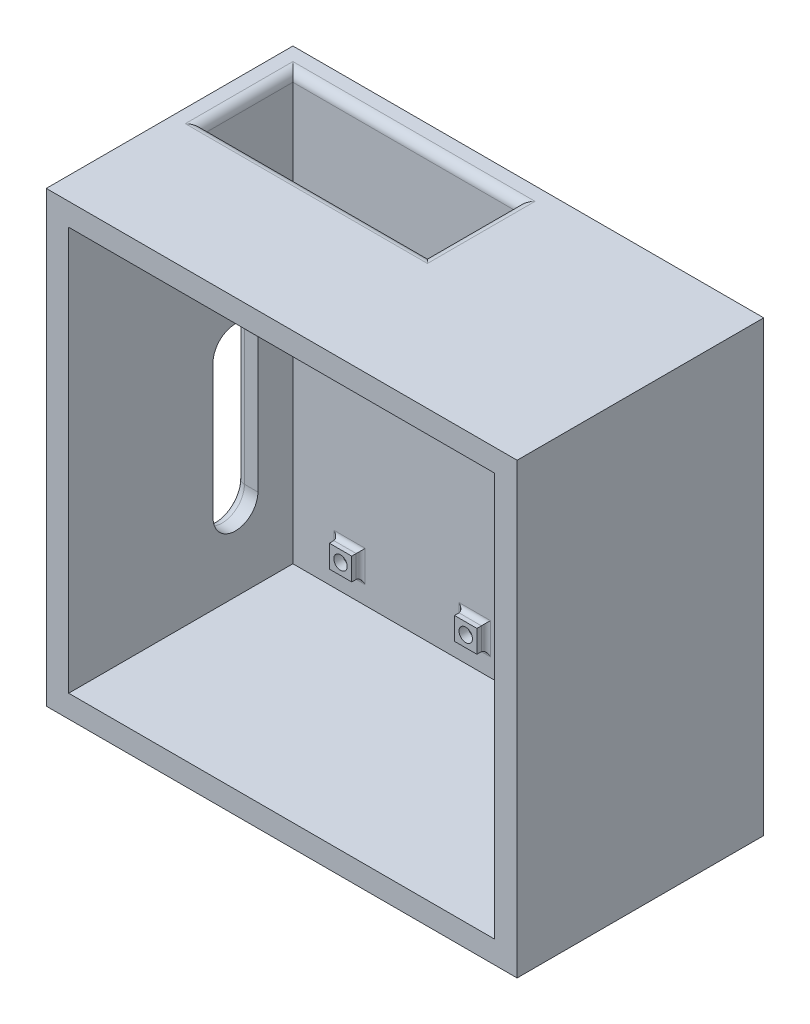
from build123d import *

# Parameters (mm, degrees)
SKETCH1_W           = 105
SKETCH1_H           = 100
SKETCH1_W_2         = 20
SKETCH1_H_2         = 40
BOSS_EXTRUDE1_DEPTH = 5
SKETCH2_W           = 105
SKETCH2_H           = 100
SKETCH2_W_2         = 95
SKETCH2_H_2         = 90
BOSS_EXTRUDE2_DEPTH = 50
SKETCH4_W           = 5
SKETCH4_H           = 5
SKETCH4_R           = 1.5
BOSS_EXTRUDE3_DEPTH = 2
FILLET1_R           = 1
SKETCH5_W           = 50
SKETCH5_H           = 20
CUT_EXTRUDE1_DEPTH  = 5
CUT_EXTRUDE2_DEPTH  = 5
FILLET2_R           = 2
FILLET3_R           = 2


with BuildPart() as part:
    # Sketch1 → Boss-Extrude1 (new body)
    with BuildSketch(Plane.XY):
        with Locations((-12.5, 20)):
            Rectangle(SKETCH1_W, SKETCH1_H)
        with Locations((10, 20)):
            Rectangle(SKETCH1_W_2, SKETCH1_H_2, mode=Mode.SUBTRACT)
    extrude(amount=BOSS_EXTRUDE1_DEPTH)

    # Sketch2 → Boss-Extrude2 (add)
    with BuildSketch(Plane.XY.offset(5)):
        with Locations((-12.5, 20)):
            Rectangle(SKETCH2_W, SKETCH2_H)
        with Locations((-12.5, 20)):
            Rectangle(SKETCH2_W_2, SKETCH2_H_2, mode=Mode.SUBTRACT)
    extrude(amount=BOSS_EXTRUDE2_DEPTH)

    # Sketch4 → Boss-Extrude3 (add)
    with BuildSketch(Plane.XY.offset(5)):
        with Locations((-52.46, 34.61)):
            Rectangle(SKETCH4_W, SKETCH4_H)
        with Locations((-52.46, 34.61)):
            Circle(SKETCH4_R, mode=Mode.SUBTRACT)
        with Locations((-4.2, 33.34)):
            Rectangle(SKETCH4_W, SKETCH4_H)
        with Locations((-4.2, 33.34)):
            Circle(SKETCH4_R, mode=Mode.SUBTRACT)
        with Locations((-47.38, -17.46)):
            Rectangle(SKETCH4_W, SKETCH4_H)
        with Locations((-47.38, -17.46)):
            Circle(SKETCH4_R, mode=Mode.SUBTRACT)
        with Locations((-19.46, -17.46)):
            Rectangle(SKETCH4_W, SKETCH4_H)
        with Locations((-19.46, -17.46)):
            Circle(SKETCH4_R, mode=Mode.SUBTRACT)
    extrude(amount=BOSS_EXTRUDE3_DEPTH)

    # Fillet1
    fillet1_edges = [part.edges().sort_by_distance(p)[0] for p in [
        (-49.96, 34.61, 5),
        (-52.46, 37.11, 5),
        (-54.96, 34.61, 5),
        (-52.46, 32.11, 5),
        (-1.7, 33.34, 5),
        (-4.2, 35.84, 5),
        (-6.7, 33.34, 5),
        (-4.2, 30.84, 5),
        (-44.88, -17.46, 5),
        (-47.38, -14.96, 5),
        (-49.88, -17.46, 5),
        (-47.38, -19.96, 5),
        (-16.96, -17.46, 5),
        (-19.46, -14.96, 5),
        (-21.96, -17.46, 5),
        (-19.46, -19.96, 5),
    ]]
    fillet(fillet1_edges, radius=FILLET1_R)

    # Sketch5 → Cut-Extrude1 (cut)
    with BuildSketch(Plane(origin=(0, 70, 0), x_dir=(1, 0, 0), z_dir=(0, 1, 0))):
        with Locations((-35, -15)):
            Rectangle(SKETCH5_W, SKETCH5_H)
    extrude(amount=-CUT_EXTRUDE1_DEPTH, mode=Mode.SUBTRACT)

    # Sketch6 → Cut-Extrude2 (cut)
    with BuildSketch(Plane.ZY.offset(65)):
        with BuildLine():
            Line((22.805324428, 22.755889518), (22.805324428, -7.244110482))
            ThreePointArc((22.805324428, -7.244110482), (17.805324428, -12.244110482), (12.805324428, -7.244110482))
            Line((12.805324428, -7.244110482), (12.805324428, 22.755889518))
            ThreePointArc((12.805324428, 22.755889518), (17.805324428, 27.755889518), (22.805324428, 22.755889518))
        make_face()
    extrude(amount=-CUT_EXTRUDE2_DEPTH, mode=Mode.SUBTRACT)

    # Fillet2
    fillet2_edges = [part.edges().sort_by_distance(p)[0] for p in [
        (-65, 27.755889518, 17.805324428),
        (-65, 7.755889518, 12.805324428),
        (-65, -12.244110482, 17.805324428),
        (-65, 7.755889518, 22.805324428),
    ]]
    fillet(fillet2_edges, radius=FILLET2_R)

    # Fillet3
    fillet3_edges = [part.edges().sort_by_distance(p)[0] for p in [
        (-60, 70, 15),
        (-35, 70, 25),
        (-10, 70, 15),
        (-35, 70, 5),
    ]]
    fillet(fillet3_edges, radius=FILLET3_R)


solid = part.part
